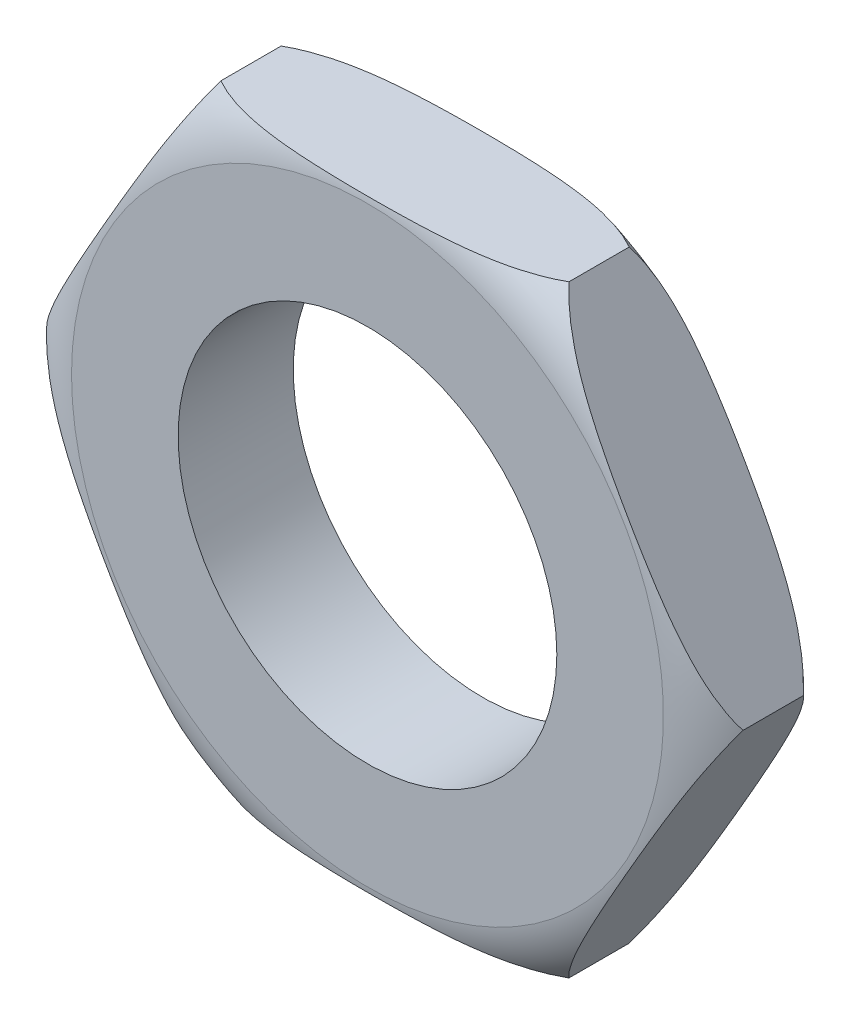
from build123d import *

# Parameters (mm, degrees)
BOSS_EXTRUDE1_DEPTH      = 1.05
F_5_16_24_TAPPED_HOLE1_D = 6.9088


with BuildPart() as part:
    # Sketch2 → Boss-Extrude1 (new body, symmetric)
    with BuildSketch(Plane.XY):
        Polygon((-3.175426481, -5.5), (3.175426481, -5.5), (6.350852961, 0), (3.175426481, 5.5), (-3.175426481, 5.5), (-6.350852961, 0), align=None)
    extrude(amount=BOSS_EXTRUDE1_DEPTH, both=True)

    # 5/16-24 Tapped Hole1 (through all)
    with Locations(Plane.XY.offset(1.05)):
        with Locations((0, 0)):
            Hole(F_5_16_24_TAPPED_HOLE1_D / 2)

    # Sketch7 → Cut-Revolve2 (revolve, cut)
    with BuildSketch(Plane(origin=(0, 0, 0), x_dir=(1, 0, 0), z_dir=(0, 1, 0))):
        with BuildLine():
            Line((-6.350852961, -0.55), (-6.350852961, -1.05))
            Line((-6.350852961, -1.05), (-5.4, -1.05))
            ThreePointArc((-5.4, -1.05), (-5.921724154, -0.888044561), (-6.350852961, -0.55))
        make_face()
    cut_revolve2 = revolve(axis=Axis((0, 0, 0), (0, 0, 1)), mode=Mode.SUBTRACT)

    # Mirror1: Cut-Revolve2 across plane
    add(cut_revolve2.mirror(Plane.XY), mode=Mode.SUBTRACT)


solid = part.part
